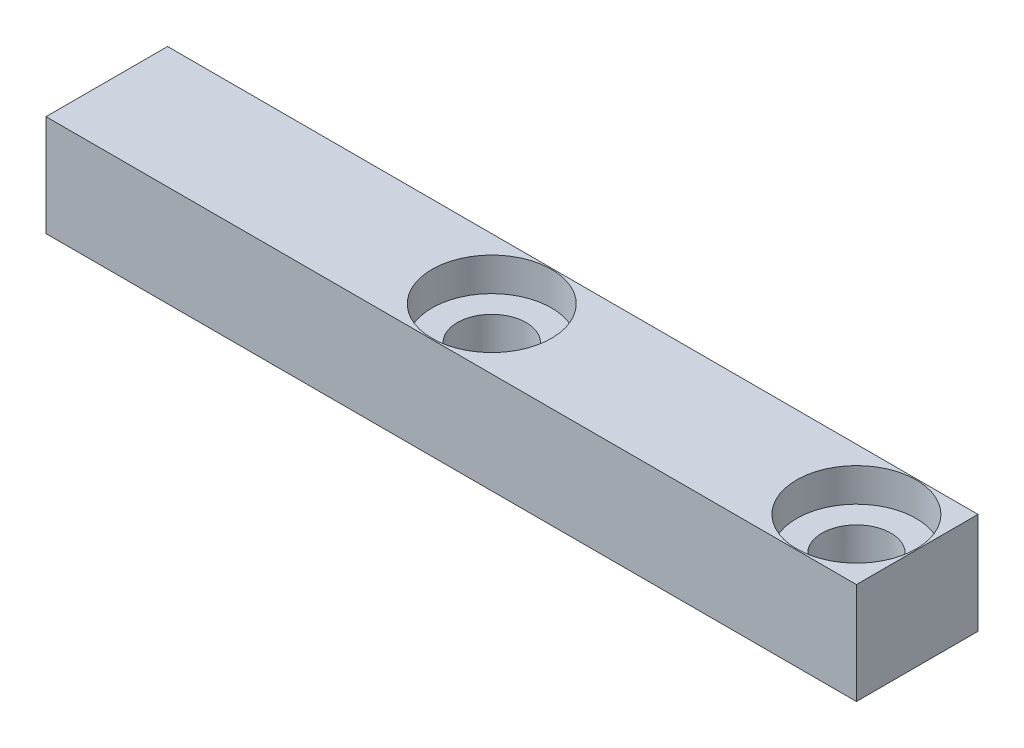
from build123d import *

# Parameters (mm, degrees)
SKETCH1_W                       = 40
SKETCH1_H                       = 6
BOSS_EXTRUDE1_DEPTH             = 5
CBORE_FOR_M3_SBHCS1_D           = 3.4
CBORE_FOR_M3_SBHCS1_DEPTH       = 7.5
CBORE_FOR_M3_SBHCS1_CBORE_D     = 5.9
CBORE_FOR_M3_SBHCS1_CBORE_DEPTH = 1.65
CBORE_FOR_M3_SBHCS1_TIP         = 1.021463052


with BuildPart() as part:
    # Sketch1 → Boss-Extrude1 (new body)
    with BuildSketch(Plane(origin=(0, 0, 0), x_dir=(1, 0, 0), z_dir=(0, 1, 0))):
        with Locations((20, 3)):
            Rectangle(SKETCH1_W, SKETCH1_H)
    extrude(amount=BOSS_EXTRUDE1_DEPTH)

    # CBORE for M3 SBHCS1
    with Locations(Plane(origin=(0, 5, 0), x_dir=(1, 0, 0), z_dir=(0, 1, 0))):
        with Locations((37, 3), (19, 3)):
            CounterBoreHole(CBORE_FOR_M3_SBHCS1_D / 2, CBORE_FOR_M3_SBHCS1_CBORE_D / 2, CBORE_FOR_M3_SBHCS1_CBORE_DEPTH, depth=CBORE_FOR_M3_SBHCS1_DEPTH)
            with Locations((0, 0, -(CBORE_FOR_M3_SBHCS1_DEPTH + CBORE_FOR_M3_SBHCS1_TIP / 2))):  # 118° drill point
                Cone(0, CBORE_FOR_M3_SBHCS1_D / 2, CBORE_FOR_M3_SBHCS1_TIP, mode=Mode.SUBTRACT)


solid = part.part
